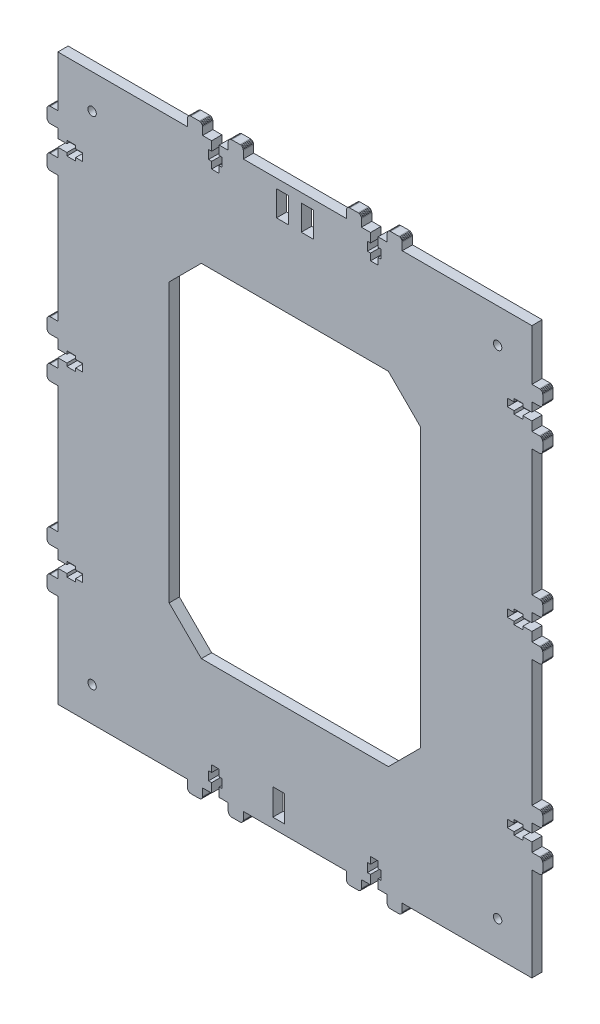
from build123d import *

# Parameters (mm, degrees)
MODEL_R                  = 2.45
MODEL_W                  = 6.99999792
MODEL_H                  = 14.799995264
MODEL_W_2                = 6.899997952
MODEL_H_2                = 15.39999384
RESSALTO_EXTRUS_O1_DEPTH = 6


with BuildPart() as part:
    # Model → Ressalto-extrusão1 (new body)
    with BuildSketch(Plane.XY):
        Polygon((136.592562973, 337.851845197), (136.592562973, 343.151844019), (141.892560228, 343.151844019), (141.892560228, 347.50184191), (141.960708575, 348.01948), (142.16050942, 348.50184191), (142.478346666, 348.916055472), (142.892560228, 349.233892717), (143.374922138, 349.433693562), (143.892560228, 349.50184191), (148.69255467, 349.50184191), (149.21019276, 349.433693562), (149.69255467, 349.233892717), (150.106768232, 348.916055472), (150.424605478, 348.50184191), (150.624406323, 348.01948), (150.69255467, 347.50184191), (150.69255467, 343.151844019), (210.892540633, 343.151844019), (210.892540633, 347.50184191), (210.960688981, 348.01948), (211.160489826, 348.50184191), (211.478327071, 348.916055472), (211.892540633, 349.233892717), (212.374902543, 349.433693562), (212.892540633, 349.50184191), (217.692536599, 349.50184191), (218.210174689, 349.433693562), (218.692536599, 349.233892717), (219.106750161, 348.916055472), (219.424587406, 348.50184191), (219.624388251, 348.01948), (219.692536599, 347.50184191), (219.692536599, 343.151844019), (224.992528605, 343.151844019), (224.992528605, 337.851845197), (223.192530373, 337.851845197), (223.192530373, 332.751847432), (224.992528605, 332.751847432), (224.992528605, 328.80184761), (229.392533277, 328.80184761), (229.392533277, 332.751847432), (231.192531509, 332.751847432), (231.192531509, 337.851845197), (229.392533277, 337.851845197), (229.392533277, 343.151844019), (234.692530532, 343.151844019), (234.692530532, 347.50184191), (234.760678879, 348.01948), (234.960479724, 348.50184191), (235.27831697, 348.916055472), (235.692530532, 349.233892717), (236.174892442, 349.433693562), (236.692530532, 349.50184191), (241.492524974, 349.50184191), (242.010163064, 349.433693562), (242.492524974, 349.233892717), (242.906738536, 348.916055472), (243.224575782, 348.50184191), (243.424376627, 348.01948), (243.492524974, 347.50184191), (243.492524974, 343.151844019), (319.192501501, 343.151844019), (319.192501501, 313.451849046), (323.542499392, 313.451849046), (324.060137483, 313.383700699), (324.542499392, 313.183899854), (324.956712955, 312.866062609), (325.2745502, 312.451849046), (325.474351045, 311.969487136), (325.542499392, 311.451849046), (325.542499392, 306.651853081), (325.474351045, 306.134214991), (325.2745502, 305.651853081), (324.956712955, 305.237639519), (324.542499392, 304.919802274), (324.060137483, 304.720001429), (323.542499392, 304.651853081), (319.192501501, 304.651853081), (319.192501501, 299.351861074), (313.892502679, 299.351861074), (313.892502679, 301.151859306), (308.792504915, 301.151859306), (308.792504915, 299.351861074), (304.842505093, 299.351861074), (304.842505093, 294.951856403), (308.792504915, 294.951856403), (308.792504915, 293.151858171), (313.892502679, 293.151858171), (313.892502679, 294.951856403), (319.192501501, 294.951856403), (319.192501501, 289.651859148), (323.542499392, 289.651859148), (324.060137483, 289.5837108), (324.542499392, 289.383909955), (324.956712955, 289.06607271), (325.2745502, 288.651859148), (325.474351045, 288.169497238), (325.542499392, 287.651859148), (325.542499392, 282.851864706), (325.474351045, 282.334226615), (325.2745502, 281.851864706), (324.956712955, 281.437651143), (324.542499392, 281.119813898), (324.060137483, 280.920013053), (323.542499392, 280.851864706), (319.192501501, 280.851864706), (319.192501501, 207.00188311), (323.542499392, 207.00188311), (324.060137483, 206.933734763), (324.542499392, 206.733933918), (324.956712955, 206.416096673), (325.2745502, 206.00188311), (325.474351045, 205.5195212), (325.542499392, 205.00188311), (325.542499392, 200.201887145), (325.474351045, 199.684249055), (325.2745502, 199.201887145), (324.956712955, 198.787673583), (324.542499392, 198.469836338), (324.060137483, 198.270035493), (323.542499392, 198.201887145), (319.192501501, 198.201887145), (319.192501501, 192.901895138), (313.892502679, 192.901895138), (313.892502679, 194.70189337), (308.792504915, 194.70189337), (308.792504915, 192.901895138), (304.842505093, 192.901895138), (304.842505093, 188.501890467), (308.792504915, 188.501890467), (308.792504915, 186.701892235), (313.892502679, 186.701892235), (313.892502679, 188.501890467), (319.192501501, 188.501890467), (319.192501501, 183.201893212), (323.542499392, 183.201893212), (324.060137483, 183.133744864), (324.542499392, 182.933944019), (324.956712955, 182.616106774), (325.2745502, 182.201893212), (325.474351045, 181.719531302), (325.542499392, 181.201893212), (325.542499392, 176.40189877), (325.474351045, 175.884260679), (325.2745502, 175.40189877), (324.956712955, 174.987685207), (324.542499392, 174.669847962), (324.060137483, 174.470047117), (323.542499392, 174.40189877), (319.192501501, 174.40189877), (319.192501501, 100.551917174), (323.542499392, 100.551917174), (324.060137483, 100.483768827), (324.542499392, 100.283967982), (324.956712955, 99.966130737), (325.2745502, 99.551917174), (325.474351045, 99.069555264), (325.542499392, 98.551917174), (325.542499392, 93.751921209), (325.474351045, 93.234283119), (325.2745502, 92.751921209), (324.956712955, 92.337707647), (324.542499392, 92.019870402), (324.060137483, 91.820069557), (323.542499392, 91.751921209), (319.192501501, 91.751921209), (319.192501501, 86.451929202), (313.892502679, 86.451929202), (313.892502679, 88.251927434), (308.792504915, 88.251927434), (308.792504915, 86.451929202), (304.842505093, 86.451929202), (304.842505093, 82.051924531), (308.792504915, 82.051924531), (308.792504915, 80.251926299), (313.892502679, 80.251926299), (313.892502679, 82.051924531), (319.192501501, 82.051924531), (319.192501501, 76.751927276), (323.542499392, 76.751927276), (324.060137483, 76.683778928), (324.542499392, 76.483978083), (324.956712955, 76.166140838), (325.2745502, 75.751927276), (325.474351045, 75.269565366), (325.542499392, 74.751927276), (325.542499392, 69.951932834), (325.474351045, 69.434294743), (325.2745502, 68.951932834), (324.956712955, 68.537719271), (324.542499392, 68.219882026), (324.060137483, 68.020081181), (323.542499392, 67.951932834), (319.192501501, 67.951932834), (319.192501501, 13.251949587), (243.492521249, 13.251949587), (243.492521249, 8.901951695), (243.424372901, 8.384313605), (243.224572056, 7.901951695), (242.906734811, 7.487738133), (242.492521249, 7.169900888), (242.010159339, 6.970100043), (241.492521249, 6.901951695), (236.692525284, 6.901951695), (236.174887194, 6.970100043), (235.692525284, 7.169900888), (235.278311721, 7.487738133), (234.960474476, 7.901951695), (234.760673631, 8.384313605), (234.692525284, 8.901951695), (234.692525284, 13.251949587), (229.392533277, 13.251949587), (229.392533277, 18.551948408), (231.192531509, 18.551948408), (231.192531509, 23.651946173), (229.392533277, 23.651946173), (229.392533277, 27.601945995), (224.992528605, 27.601945995), (224.992528605, 23.651946173), (223.192530373, 23.651946173), (223.192530373, 18.551948408), (224.992528605, 18.551948408), (224.992528605, 13.251949587), (219.69253135, 13.251949587), (219.69253135, 8.901951695), (219.624383003, 8.384313605), (219.424582158, 7.901951695), (219.106744913, 7.487738133), (218.69253135, 7.169900888), (218.210169441, 6.970100043), (217.69253135, 6.901951695), (212.892536908, 6.901951695), (212.374898818, 6.970100043), (211.892536908, 7.169900888), (211.478323346, 7.487738133), (211.160486101, 7.901951695), (210.960685256, 8.384313605), (210.892536908, 8.901951695), (210.892536908, 13.251949587), (150.692550945, 13.251949587), (150.692550945, 8.901951695), (150.624402597, 8.384313605), (150.424601752, 7.901951695), (150.106764507, 7.487738133), (149.692550945, 7.169900888), (149.210189035, 6.970100043), (148.692550945, 6.901951695), (143.89255498, 6.901951695), (143.37491689, 6.970100043), (142.89255498, 7.169900888), (142.478341417, 7.487738133), (142.160504172, 7.901951695), (141.960703327, 8.384313605), (141.89255498, 8.901951695), (141.89255498, 13.251949587), (136.592562973, 13.251949587), (136.592562973, 18.551948408), (138.392561205, 18.551948408), (138.392561205, 23.651946173), (136.592562973, 23.651946173), (136.592562973, 27.601945995), (132.192558301, 27.601945995), (132.192558301, 23.651946173), (130.392560069, 23.651946173), (130.392560069, 18.551948408), (132.192558301, 18.551948408), (132.192558301, 13.251949587), (126.892561046, 13.251949587), (126.892561046, 8.901951695), (126.824412699, 8.384313605), (126.624611854, 7.901951695), (126.306774609, 7.487738133), (125.892561046, 7.169900888), (125.410199137, 6.970100043), (124.892561046, 6.901951695), (120.092566604, 6.901951695), (119.574928514, 6.970100043), (119.092566604, 7.169900888), (118.678353042, 7.487738133), (118.360515797, 7.901951695), (118.160714952, 8.384313605), (118.092566604, 8.901951695), (118.092566604, 13.251949587), (42.392590077, 13.251949587), (42.392590077, 67.951936559), (38.042592186, 67.951936559), (37.524954096, 68.020084906), (37.042592186, 68.219885751), (36.628378624, 68.537722996), (36.310541378, 68.951936559), (36.110740533, 69.434298469), (36.042592186, 69.951936559), (36.042592186, 74.751932524), (36.110740533, 75.269570614), (36.310541378, 75.751932524), (36.628378624, 76.166146086), (37.042592186, 76.483983331), (37.524954096, 76.683784176), (38.042592186, 76.751932524), (42.392590077, 76.751932524), (42.392590077, 82.051924531), (47.692588899, 82.051924531), (47.692588899, 80.251926299), (52.792586663, 80.251926299), (52.792586663, 82.051924531), (56.742586486, 82.051924531), (56.742586486, 86.451929202), (52.792586663, 86.451929202), (52.792586663, 88.251927434), (47.692588899, 88.251927434), (47.692588899, 86.451929202), (42.392590077, 86.451929202), (42.392590077, 91.751926457), (38.042592186, 91.751926457), (37.524954096, 91.820074805), (37.042592186, 92.01987565), (36.628378624, 92.337712895), (36.310541378, 92.751926457), (36.110740533, 93.234288367), (36.042592186, 93.751926457), (36.042592186, 98.551920899), (36.110740533, 99.06955899), (36.310541378, 99.551920899), (36.628378624, 99.966134462), (37.042592186, 100.283971707), (37.524954096, 100.483772552), (38.042592186, 100.551920899), (42.392590077, 100.551920899), (42.392590077, 174.401902495), (38.042592186, 174.401902495), (37.524954096, 174.470050842), (37.042592186, 174.669851687), (36.628378624, 174.987688932), (36.310541378, 175.401902495), (36.110740533, 175.884264405), (36.042592186, 176.401902495), (36.042592186, 181.20189846), (36.110740533, 181.71953655), (36.310541378, 182.20189846), (36.628378624, 182.616112022), (37.042592186, 182.933949267), (37.524954096, 183.133750112), (38.042592186, 183.20189846), (42.392590077, 183.20189846), (42.392590077, 188.501890467), (47.692588899, 188.501890467), (47.692588899, 186.701892235), (52.792586663, 186.701892235), (52.792586663, 188.501890467), (56.742586486, 188.501890467), (56.742586486, 192.901895138), (52.792586663, 192.901895138), (52.792586663, 194.70189337), (47.692588899, 194.70189337), (47.692588899, 192.901895138), (42.392590077, 192.901895138), (42.392590077, 198.201892393), (38.042592186, 198.201892393), (37.524954096, 198.270040741), (37.042592186, 198.469841586), (36.628378624, 198.787678831), (36.310541378, 199.201892393), (36.110740533, 199.684254303), (36.042592186, 200.201892393), (36.042592186, 205.001886835), (36.110740533, 205.519524926), (36.310541378, 206.001886835), (36.628378624, 206.416100398), (37.042592186, 206.733937643), (37.524954096, 206.933738488), (38.042592186, 207.001886835), (42.392590077, 207.001886835), (42.392590077, 280.851868431), (38.042592186, 280.851868431), (37.524954096, 280.920016778), (37.042592186, 281.119817623), (36.628378624, 281.437654868), (36.310541378, 281.851868431), (36.110740533, 282.334230341), (36.042592186, 282.851868431), (36.042592186, 287.651864396), (36.110740533, 288.169502486), (36.310541378, 288.651864396), (36.628378624, 289.066077958), (37.042592186, 289.383915203), (37.524954096, 289.583716048), (38.042592186, 289.651864396), (42.392590077, 289.651864396), (42.392590077, 294.951856403), (47.692588899, 294.951856403), (47.692588899, 293.151858171), (52.792586663, 293.151858171), (52.792586663, 294.951856403), (56.742586486, 294.951856403), (56.742586486, 299.351861074), (52.792586663, 299.351861074), (52.792586663, 301.151859306), (47.692588899, 301.151859306), (47.692588899, 299.351861074), (42.392590077, 299.351861074), (42.392590077, 304.651858329), (38.042592186, 304.651858329), (37.524954096, 304.720006677), (37.042592186, 304.919807522), (36.628378624, 305.237644767), (36.310541378, 305.651858329), (36.110740533, 306.134220239), (36.042592186, 306.651858329), (36.042592186, 311.451852771), (36.110740533, 311.969490862), (36.310541378, 312.451852771), (36.628378624, 312.866066334), (37.042592186, 313.183903579), (37.524954096, 313.383704424), (38.042592186, 313.451852771), (42.392590077, 313.451852771), (42.392590077, 343.151844019), (118.092570329, 343.151844019), (118.092570329, 347.50184191), (118.160718677, 348.01948), (118.360519522, 348.50184191), (118.678356767, 348.916055472), (119.092570329, 349.233892717), (119.574932239, 349.433693562), (120.092570329, 349.50184191), (124.892566294, 349.50184191), (125.410204385, 349.433693562), (125.892566294, 349.233892717), (126.306779857, 348.916055472), (126.624617102, 348.50184191), (126.824417947, 348.01948), (126.892566294, 347.50184191), (126.892566294, 343.151844019), (132.192558301, 343.151844019), (132.192558301, 337.851845197), (130.392560069, 337.851845197), (130.392560069, 332.751847432), (132.192558301, 332.751847432), (132.192558301, 328.80184761), (136.592562973, 328.80184761), (136.592562973, 332.751847432), (138.392561205, 332.751847432), (138.392561205, 337.851845197), align=None)
        with Locations((299.192501501, 323.151844019)):
            Circle(MODEL_R, mode=Mode.SUBTRACT)
        with Locations((299.192501501, 33.251949587)):
            Circle(MODEL_R, mode=Mode.SUBTRACT)
        with Locations((62.392590077, 33.251949587)):
            Circle(MODEL_R, mode=Mode.SUBTRACT)
        with Locations((62.392590077, 323.151844019)):
            Circle(MODEL_R, mode=Mode.SUBTRACT)
        with Locations((188.042545332, 330.451848083)):
            Rectangle(MODEL_W, MODEL_H, mode=Mode.SUBTRACT)
        with Locations((173.542549972, 330.451848083)):
            Rectangle(MODEL_W, MODEL_H, mode=Mode.SUBTRACT)
        with Locations((171.39255066, 26.651944683)):
            Rectangle(MODEL_W_2, MODEL_H_2, mode=Mode.SUBTRACT)
        Polygon((254.192501501, 97.038746151), (254.192501501, 259.365047454), (235.405704937, 278.151844019), (126.179386642, 278.151844019), (107.392590077, 259.365047454), (107.392590077, 97.038746151), (126.179386642, 78.251949587), (235.405704937, 78.251949587), align=None, mode=Mode.SUBTRACT)
    extrude(amount=RESSALTO_EXTRUS_O1_DEPTH)


solid = part.part
